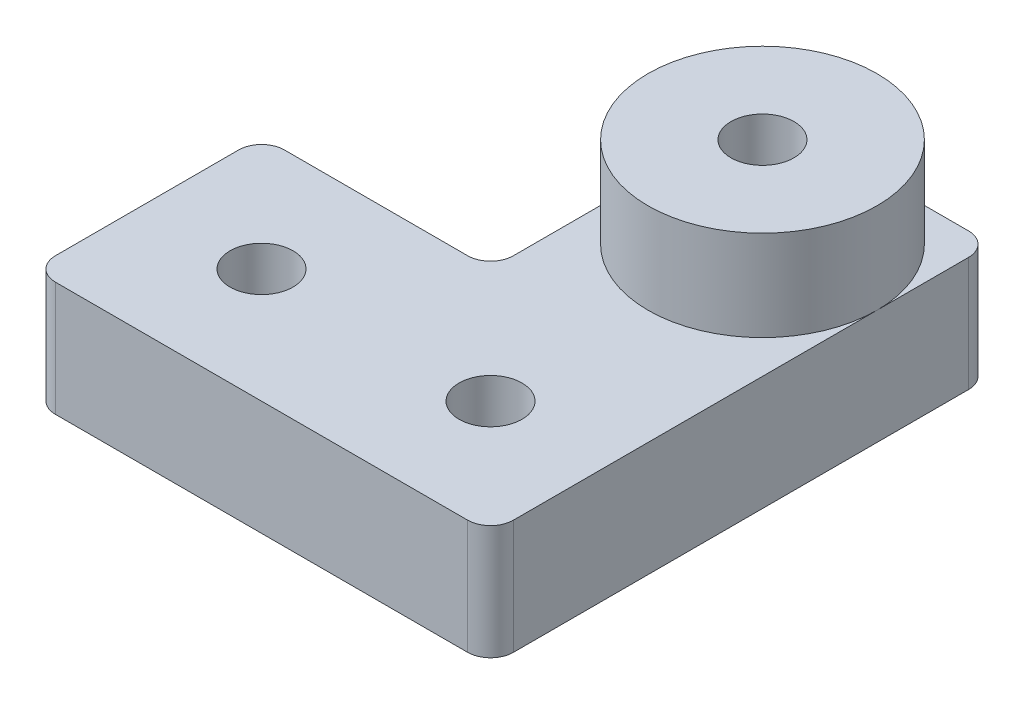
from build123d import *

# Parameters (mm, degrees)
BOSS_EXTRUDE1_DEPTH            = 10
CBORE_FOR_M5_SHCS1_AT_2_COUNT  = 2
CBORE_FOR_M5_SHCS1_AT_2_PITCH  = 20
FILLET1_R                      = 2
CUT_EXTRUDE1_DEPTH             = 4.2
M5_CLEARANCE_HOLE1_D           = 5.5
M5_CLEARANCE_HOLE1_CSINK_D     = 5.55
M5_CLEARANCE_HOLE1_CSINK_ANGLE = 90
SKETCH9_R                      = 10
SKETCH9_R_2                    = 2.75
BOSS_EXTRUDE2_DEPTH            = 7.9


with BuildPart() as part:
    # Sketch1 → Boss-Extrude1 (new body)
    with BuildSketch(Plane(origin=(0, 0, 0), x_dir=(1, 0, 0), z_dir=(0, 1, 0))):
        Polygon((0, 0), (40, 0), (40, 43.75), (20, 43.75), (20, 20), (0, 20), align=None)
    extrude(amount=BOSS_EXTRUDE1_DEPTH)

    # Sketch4 → CBORE for M5 SHCS1 (revolve, cut)
    with BuildSketch(Plane(origin=(10, 0, -10), x_dir=(0, 0, -1), z_dir=(1, 0, 0))):
        Polygon((0, 0), (0, 10), (2.75, 10), (2.75, 5), (5, 5), (5, 0.025), (5.025, 0), align=None)
    cbore_for_m5_shcs1 = revolve(axis=Axis((10, -6.35, -10), (0, 1, 0)), mode=Mode.SUBTRACT)

    # CBORE for M5 SHCS1 at 2: CBORE for M5 SHCS1 ×2
    with Locations(*[(i * CBORE_FOR_M5_SHCS1_AT_2_PITCH, 0, 0) for i in range(1, CBORE_FOR_M5_SHCS1_AT_2_COUNT)]):
        add(cbore_for_m5_shcs1, mode=Mode.SUBTRACT)

    # Fillet1
    fillet1_edges = [part.edges().sort_by_distance(p)[0] for p in [
        (0, 5, -20),
        (20, 5, -20),
        (20, 5, -43.75),
        (40, 5, -43.75),
        (40, 5, 0),
        (0, 5, 0),
    ]]
    fillet(fillet1_edges, radius=FILLET1_R)

    # Sketch6 → Cut-Extrude1 (cut)
    with BuildSketch(Plane.XZ):
        Polygon((34.7, -33.75), (32.35, -29.679680602), (27.65, -29.679680602), (25.3, -33.75), (27.65, -37.820319398), (32.35, -37.820319398), align=None)
    extrude(amount=-CUT_EXTRUDE1_DEPTH, mode=Mode.SUBTRACT)

    # M5 Clearance Hole1 (through all)
    with Locations(Plane(origin=(0, 0, 0), x_dir=(-1, 0, 0), z_dir=(0, -1, 0))):
        with Locations((-30, 33.75)):
            CounterSinkHole(M5_CLEARANCE_HOLE1_D / 2, M5_CLEARANCE_HOLE1_CSINK_D / 2, counter_sink_angle=M5_CLEARANCE_HOLE1_CSINK_ANGLE)

    # Sketch9 → Boss-Extrude2 (add)
    with BuildSketch(Plane(origin=(0, 10, 0), x_dir=(1, 0, 0), z_dir=(0, 1, 0))):
        with Locations((30, 33.75)):
            Circle(SKETCH9_R)
        with Locations((30, 33.75)):
            Circle(SKETCH9_R_2, mode=Mode.SUBTRACT)
    extrude(amount=BOSS_EXTRUDE2_DEPTH)


solid = part.part
